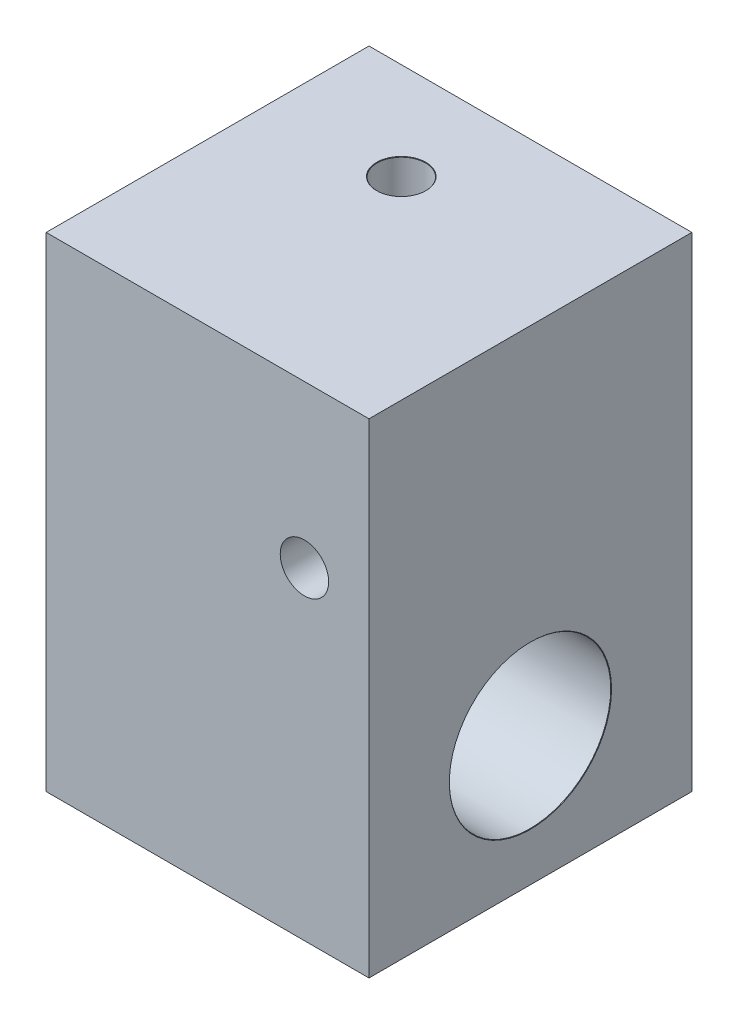
from build123d import *

# Parameters (mm, degrees)
SKETCH1_W                        = 20
SKETCH1_H                        = 20
BOSS_EXTRUDE1_DEPTH              = 30
F_3_0MM_DOWEL_HOLE1_D            = 3
F_3_0MM_DOWEL_HOLE1_DEPTH        = 20
F_3_0MM_DOWEL_HOLE1_CSINK_D      = 3.05
F_3_0MM_DOWEL_HOLE1_CSINK_ANGLE  = 90
F_3_0MM_DOWEL_HOLE1_TIP          = 0.901290929
F_3_0MM_DOWEL_HOLE2_D            = 3
F_3_0MM_DOWEL_HOLE2_DEPTH        = 12
F_3_0MM_DOWEL_HOLE2_CSINK_D      = 3.05
F_3_0MM_DOWEL_HOLE2_CSINK_ANGLE  = 90
F_3_0MM_DOWEL_HOLE2_TIP          = 0.901290929
F_3_0MM_DOWEL_HOLE3_D            = 3
F_3_0MM_DOWEL_HOLE3_DEPTH        = 20
F_3_0MM_DOWEL_HOLE3_CSINK_D      = 3.05
F_3_0MM_DOWEL_HOLE3_CSINK_ANGLE  = 90
F_3_0MM_DOWEL_HOLE3_TIP          = 0.901290929
F_10_0MM_DOWEL_HOLE1_D           = 10
F_10_0MM_DOWEL_HOLE1_DEPTH       = 17
F_10_0MM_DOWEL_HOLE1_CSINK_D     = 10.05
F_10_0MM_DOWEL_HOLE1_CSINK_ANGLE = 90
F_10_0MM_DOWEL_HOLE1_TIP         = 3.004303095


with BuildPart() as part:
    # Sketch1 → Boss-Extrude1 (new body)
    with BuildSketch(Plane(origin=(0, 0, 0), x_dir=(1, 0, 0), z_dir=(0, 1, 0))):
        with Locations((10, -8.099538279)):
            Rectangle(SKETCH1_W, SKETCH1_H)
    extrude(amount=BOSS_EXTRUDE1_DEPTH)

    # Ø3.0mm Dowel Hole1
    with Locations(Plane(origin=(0, 0, -1.900461721), x_dir=(-1, 0, 0), z_dir=(0, 0, -1))):
        with Locations((-16, 20)):
            CounterSinkHole(F_3_0MM_DOWEL_HOLE1_D / 2, F_3_0MM_DOWEL_HOLE1_CSINK_D / 2, depth=F_3_0MM_DOWEL_HOLE1_DEPTH, counter_sink_angle=F_3_0MM_DOWEL_HOLE1_CSINK_ANGLE)
            with Locations((0, 0, -(F_3_0MM_DOWEL_HOLE1_DEPTH + F_3_0MM_DOWEL_HOLE1_TIP / 2))):  # 118° drill point
                Cone(0, F_3_0MM_DOWEL_HOLE1_D / 2, F_3_0MM_DOWEL_HOLE1_TIP, mode=Mode.SUBTRACT)

    # Ø3.0mm Dowel Hole2
    with Locations(Plane.ZY):
        with Locations((8.099538279, 25)):
            CounterSinkHole(F_3_0MM_DOWEL_HOLE2_D / 2, F_3_0MM_DOWEL_HOLE2_CSINK_D / 2, depth=F_3_0MM_DOWEL_HOLE2_DEPTH, counter_sink_angle=F_3_0MM_DOWEL_HOLE2_CSINK_ANGLE)
            with Locations((0, 0, -(F_3_0MM_DOWEL_HOLE2_DEPTH + F_3_0MM_DOWEL_HOLE2_TIP / 2))):  # 118° drill point
                Cone(0, F_3_0MM_DOWEL_HOLE2_D / 2, F_3_0MM_DOWEL_HOLE2_TIP, mode=Mode.SUBTRACT)

    # Ø3.0mm Dowel Hole3
    with Locations(Plane(origin=(0, 30, 0), x_dir=(1, 0, 0), z_dir=(0, 1, 0))):
        with Locations((8, -4.099538279)):
            CounterSinkHole(F_3_0MM_DOWEL_HOLE3_D / 2, F_3_0MM_DOWEL_HOLE3_CSINK_D / 2, depth=F_3_0MM_DOWEL_HOLE3_DEPTH, counter_sink_angle=F_3_0MM_DOWEL_HOLE3_CSINK_ANGLE)
            with Locations((0, 0, -(F_3_0MM_DOWEL_HOLE3_DEPTH + F_3_0MM_DOWEL_HOLE3_TIP / 2))):  # 118° drill point
                Cone(0, F_3_0MM_DOWEL_HOLE3_D / 2, F_3_0MM_DOWEL_HOLE3_TIP, mode=Mode.SUBTRACT)

    # Ø10.0mm Dowel Hole1
    with Locations(Plane(origin=(20, 0, 0), x_dir=(0, 0, -1), z_dir=(1, 0, 0))):
        with Locations((-8.099538279, 8)):
            CounterSinkHole(F_10_0MM_DOWEL_HOLE1_D / 2, F_10_0MM_DOWEL_HOLE1_CSINK_D / 2, depth=F_10_0MM_DOWEL_HOLE1_DEPTH, counter_sink_angle=F_10_0MM_DOWEL_HOLE1_CSINK_ANGLE)
            with Locations((0, 0, -(F_10_0MM_DOWEL_HOLE1_DEPTH + F_10_0MM_DOWEL_HOLE1_TIP / 2))):  # 118° drill point
                Cone(0, F_10_0MM_DOWEL_HOLE1_D / 2, F_10_0MM_DOWEL_HOLE1_TIP, mode=Mode.SUBTRACT)


solid = part.part
